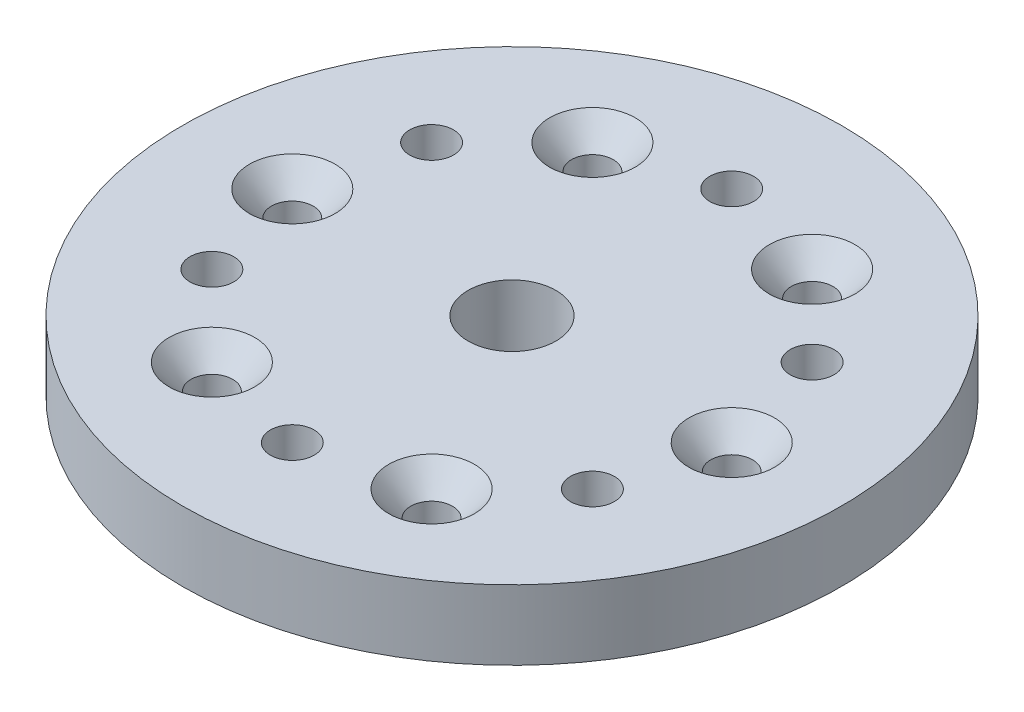
from build123d import *

# Parameters (mm, degrees)
SKETCH1_R             = 30
SKETCH1_R_2           = 1.89865
SKETCH1_R_3           = 1.9939
SKETCH1_R_4           = 4
BOSS_EXTRUDE1_DEPTH   = 6.35
CHAMFER1_SIZE         = 2.301024407
CHAMFER1_SIZE2        = 2.00025
CHAMFER1_PART_2_SIZE  = 2.301024407
CHAMFER1_PART_2_SIZE2 = 2.00025
CHAMFER1_PART_3_SIZE  = 2.301024407
CHAMFER1_PART_3_SIZE2 = 2.00025
CHAMFER1_PART_4_SIZE  = 2.301024407
CHAMFER1_PART_4_SIZE2 = 2.00025
CHAMFER1_PART_5_SIZE  = 2.301024407
CHAMFER1_PART_5_SIZE2 = 2.00025
CHAMFER1_PART_6_SIZE  = 2.301024407
CHAMFER1_PART_6_SIZE2 = 2.00025


with BuildPart() as part:
    # Sketch1 → Boss-Extrude1 (new body)
    with BuildSketch(Plane(origin=(0, 0, 0), x_dir=(1, 0, 0), z_dir=(0, 1, 0))):
        Circle(SKETCH1_R)
        with Locations((20, 0)):
            Circle(SKETCH1_R_2, mode=Mode.SUBTRACT)
        with Locations((10, -17.320508076)):
            Circle(SKETCH1_R_2, mode=Mode.SUBTRACT)
        with Locations((-10, -17.320508076)):
            Circle(SKETCH1_R_2, mode=Mode.SUBTRACT)
        with Locations((-20, 0)):
            Circle(SKETCH1_R_2, mode=Mode.SUBTRACT)
        with Locations((-10, 17.320508076)):
            Circle(SKETCH1_R_2, mode=Mode.SUBTRACT)
        with Locations((10, 17.320508076)):
            Circle(SKETCH1_R_2, mode=Mode.SUBTRACT)
        with Locations((0, 20)):
            Circle(SKETCH1_R_3, mode=Mode.SUBTRACT)
        with Locations((17.320508076, 10)):
            Circle(SKETCH1_R_3, mode=Mode.SUBTRACT)
        with Locations((17.320508076, -10)):
            Circle(SKETCH1_R_3, mode=Mode.SUBTRACT)
        with Locations((0, -20)):
            Circle(SKETCH1_R_3, mode=Mode.SUBTRACT)
        with Locations((-17.320508076, -10)):
            Circle(SKETCH1_R_3, mode=Mode.SUBTRACT)
        with Locations((-17.320508076, 10)):
            Circle(SKETCH1_R_3, mode=Mode.SUBTRACT)
        Circle(SKETCH1_R_4, mode=Mode.SUBTRACT)
    extrude(amount=BOSS_EXTRUDE1_DEPTH)

    # Chamfer1
    chamfer1_edges = [part.edges().sort_by_distance(p)[0] for p in [
        (8.10135, 6.35, 17.320508076),
    ]]
    chamfer1_side = [part.faces().sort_by_distance(p)[0] for p in [
        (8.10135, 3.175, 17.320508076),
    ]]
    chamfer(chamfer1_edges, length=CHAMFER1_SIZE, length2=CHAMFER1_SIZE2, reference=chamfer1_side[0])

    # Chamfer1 part 2
    chamfer1_part_2_edges = [part.edges().sort_by_distance(p)[0] for p in [
        (-11.89865, 6.35, 17.320508076),
    ]]
    chamfer1_part_2_side = [part.faces().sort_by_distance(p)[0] for p in [
        (-11.89865, 3.175, 17.320508076),
    ]]
    chamfer(chamfer1_part_2_edges, length=CHAMFER1_PART_2_SIZE, length2=CHAMFER1_PART_2_SIZE2, reference=chamfer1_part_2_side[0])

    # Chamfer1 part 3
    chamfer1_part_3_edges = [part.edges().sort_by_distance(p)[0] for p in [
        (-21.89865, 6.35, 0),
    ]]
    chamfer1_part_3_side = [part.faces().sort_by_distance(p)[0] for p in [
        (-21.89865, 3.175, 0),
    ]]
    chamfer(chamfer1_part_3_edges, length=CHAMFER1_PART_3_SIZE, length2=CHAMFER1_PART_3_SIZE2, reference=chamfer1_part_3_side[0])

    # Chamfer1 part 4
    chamfer1_part_4_edges = [part.edges().sort_by_distance(p)[0] for p in [
        (-11.89865, 6.35, -17.320508076),
    ]]
    chamfer1_part_4_side = [part.faces().sort_by_distance(p)[0] for p in [
        (-11.89865, 3.175, -17.320508076),
    ]]
    chamfer(chamfer1_part_4_edges, length=CHAMFER1_PART_4_SIZE, length2=CHAMFER1_PART_4_SIZE2, reference=chamfer1_part_4_side[0])

    # Chamfer1 part 5
    chamfer1_part_5_edges = [part.edges().sort_by_distance(p)[0] for p in [
        (8.10135, 6.35, -17.320508076),
    ]]
    chamfer1_part_5_side = [part.faces().sort_by_distance(p)[0] for p in [
        (8.10135, 3.175, -17.320508076),
    ]]
    chamfer(chamfer1_part_5_edges, length=CHAMFER1_PART_5_SIZE, length2=CHAMFER1_PART_5_SIZE2, reference=chamfer1_part_5_side[0])

    # Chamfer1 part 6
    chamfer1_part_6_edges = [part.edges().sort_by_distance(p)[0] for p in [
        (18.10135, 6.35, 0),
    ]]
    chamfer1_part_6_side = [part.faces().sort_by_distance(p)[0] for p in [
        (18.10135, 3.175, 0),
    ]]
    chamfer(chamfer1_part_6_edges, length=CHAMFER1_PART_6_SIZE, length2=CHAMFER1_PART_6_SIZE2, reference=chamfer1_part_6_side[0])


solid = part.part
